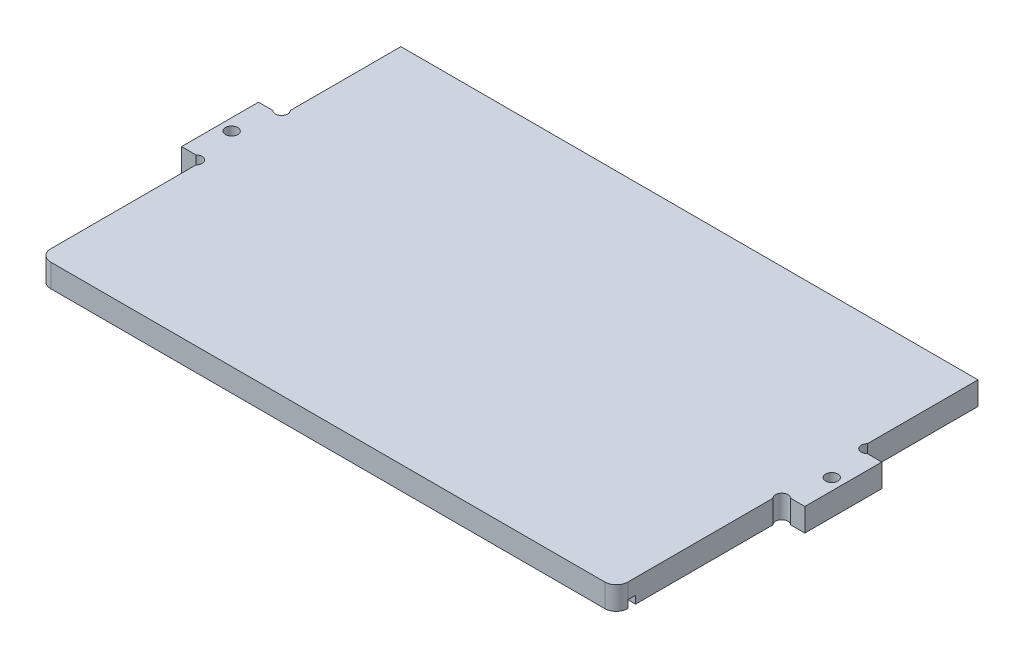
from build123d import *

# Parameters (mm, degrees)
ESQUISSE1_R             = 1.6
BOSS_EXTRU_1_DEPTH      = 6
ESQUISSE2_W             = 150
ESQUISSE2_H             = 2
ENL_V_MAT_EXTRU_1_DEPTH = 2


with BuildPart() as part:
    # Esquisse1 → Boss.-Extru.1 (new body)
    with BuildSketch(Plane(origin=(0, 0, 0), x_dir=(1, 0, 0), z_dir=(0, 1, 0))):
        with BuildLine():
            Line((6, 56.2627417), (6, 85))
            Line((6, 85), (156, 85))
            Line((156, 85), (156, 56.2627417))
            ThreePointArc((156, 56.2627417), (156, 54), (158.2627417, 54))
            Line((158.2627417, 54), (162, 54))
            Line((162, 54), (162, 34))
            Line((162, 34), (158.2627417, 34))
            ThreePointArc((158.2627417, 34), (156, 34), (156, 31.7372583))
            Line((156, 31.7372583), (156, -6))
            ThreePointArc((156, -6), (155.121320344, -8.121320344), (153, -9))
            Line((153, -9), (9, -9))
            ThreePointArc((9, -9), (6.878679656, -8.121320344), (6, -6))
            Line((6, -6), (6, 31.7372583))
            ThreePointArc((6, 31.7372583), (6, 34), (3.7372583, 34))
            Line((3.7372583, 34), (0, 34))
            Line((0, 34), (0, 54))
            Line((0, 54), (3.7372583, 54))
            ThreePointArc((3.7372583, 54), (6, 54), (6, 56.2627417))
        make_face()
        with Locations(Location((3, 44, 0), (0, 0, 270))):  # turned: the seam where the file's is
            Circle(ESQUISSE1_R, mode=Mode.SUBTRACT)
        with Locations(Location((159, 44, 0), (0, 0, 90))):  # turned: the seam where the file's is
            Circle(ESQUISSE1_R, mode=Mode.SUBTRACT)
    extrude(amount=BOSS_EXTRU_1_DEPTH)

    # Esquisse2 → Enlèv. mat.-Extru.1 (cut)
    with BuildSketch(Plane.XZ):
        with Locations((81, 5)):
            Rectangle(ESQUISSE2_W, ESQUISSE2_H)
    extrude(amount=-ENL_V_MAT_EXTRU_1_DEPTH, mode=Mode.SUBTRACT)


solid = part.part
